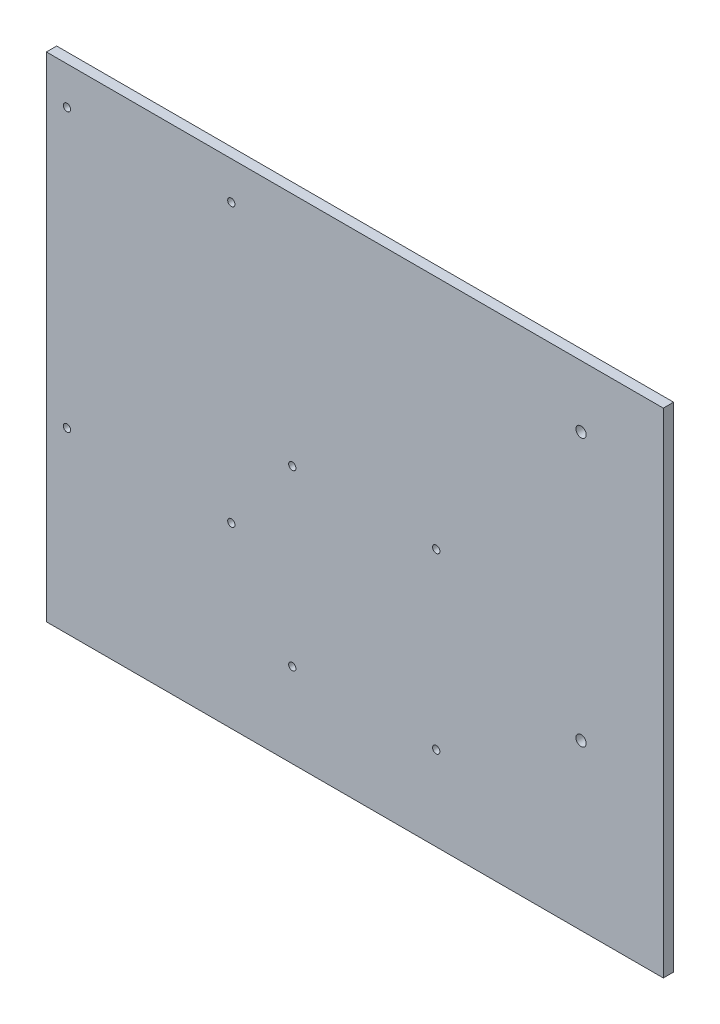
from build123d import *

# Parameters (mm, degrees)
SKETCH1_W            = 381
SKETCH1_H            = 304.8
BOSS_EXTRUDE1_DEPTH  = 6.35
M4_CLEARANCE_HOLE1_D = 4.5
SKETCH3_R            = 3.175
CUT_EXTRUDE2_DEPTH   = 7.35
SKETCH8_R            = 2.25425
CUT_EXTRUDE5_DEPTH   = 6.35


with BuildPart() as part:
    # Sketch1 → Boss-Extrude1 (new body)
    with BuildSketch(Plane.XY):
        with Locations((190.5, 152.4)):
            Rectangle(SKETCH1_W, SKETCH1_H)
    extrude(amount=BOSS_EXTRUDE1_DEPTH)

    # M4 Clearance Hole1 (through all)
    with Locations(Plane.XY.offset(6.35)):
        with Locations((12.7, 110), (114.2, 110), (12.7, 281.5), (114.2, 281.5)):
            Hole(M4_CLEARANCE_HOLE1_D / 2)

    # Sketch3 → Cut-Extrude2 (cut, through all)
    with BuildSketch(Plane.XY.offset(6.35)):
        with Locations((330.2, 101.6)):
            Circle(SKETCH3_R)
        with Locations((330.2, 266.7)):
            Circle(SKETCH3_R)
    extrude(amount=-CUT_EXTRUDE2_DEPTH, mode=Mode.SUBTRACT)

    # Sketch8 → Cut-Extrude5 (cut)
    with BuildSketch(Plane(origin=(190.518001872, -5.896320956, 6.35), x_dir=(1, 0, 0), z_dir=(0, 0, 1))):
        with Locations((-38.6718713, 165.095822345)):
            Circle(SKETCH8_R)
        with Locations((50.2281287, 165.095822345)):
            Circle(SKETCH8_R)
        with Locations((-38.6718713, 57.912922015)):
            Circle(SKETCH8_R)
        with Locations((50.2281287, 57.912922015)):
            Circle(SKETCH8_R)
    extrude(amount=-CUT_EXTRUDE5_DEPTH, mode=Mode.SUBTRACT)


solid = part.part
